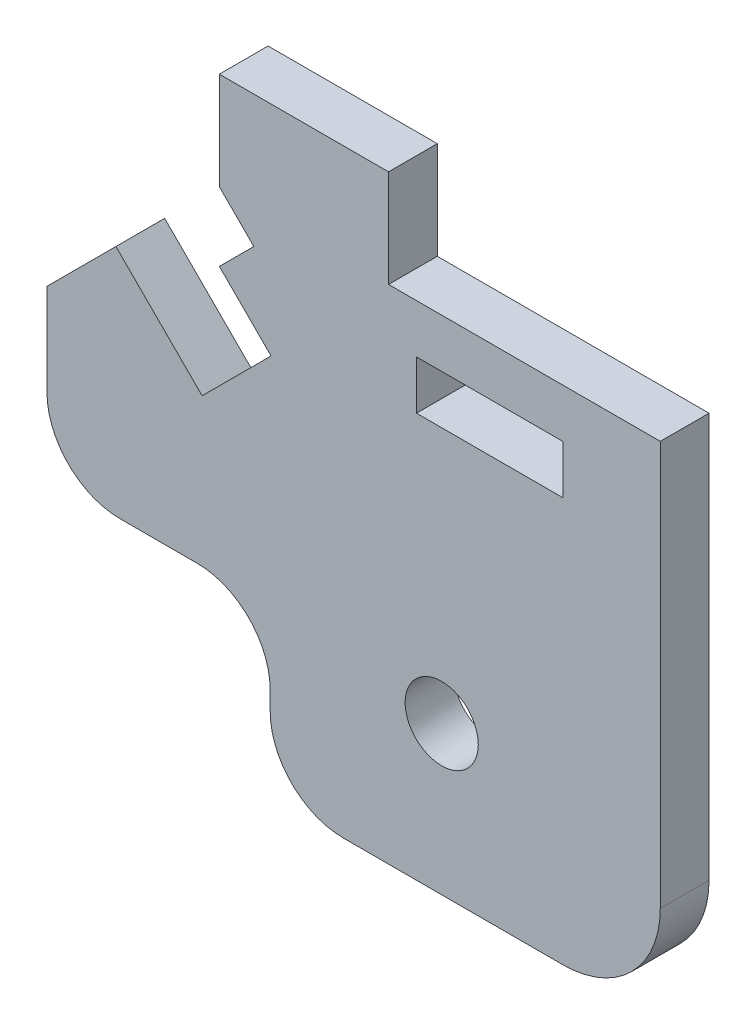
from build123d import *

# Parameters (mm, degrees)
MODEL_R             = 1.5
MODEL_W             = 6
MODEL_H             = 2
BOSS_EXTRUDE1_DEPTH = 2
SKETCH15_W          = 2
SKETCH15_H          = 3
CUT_EXTRUDE1_DEPTH  = 2


with BuildPart() as part:
    # Model → Boss-Extrude1 (new body)
    with BuildSketch(Plane.XY):
        with BuildLine():
            Line((6.363961031, 1.171572875), (2.828427125, 4.707106781))
            Line((2.828427125, 4.707106781), (0, 1.878679656))
            Line((0, 1.878679656), (0, -1.878679656))
            ThreePointArc((0, -1.878679656), (0.878679656, -4), (3, -4.878679656))
            Line((3, -4.878679656), (5.828427125, -4.878679656))
            Line((5.828427125, -4.878679656), (6.156854249, -4.878679656))
            ThreePointArc((6.156854249, -4.878679656), (8.278174593, -5.757359313), (9.156854249, -7.878679656))
            Line((9.156854249, -7.878679656), (9.156854249, -8.641362585))
            ThreePointArc((9.156854249, -8.641362585), (10.035533906, -10.762682929), (12.156854249, -11.641362585))
            Line((12.156854249, -11.641362585), (21.156854249, -11.641362585))
            ThreePointArc((21.156854249, -11.641362585), (23.985281374, -10.46978971), (25.156854249, -7.641362585))
            Line((25.156854249, -7.641362585), (25.156854249, 8.949747468))
            Line((25.156854249, 8.949747468), (14.01040764, 8.949747468))
            Line((14.01040764, 8.949747468), (14.01040764, 12.949747468))
            Line((14.01040764, 12.949747468), (7.071067812, 12.949747468))
            Line((7.071067812, 12.949747468), (7.071067812, 8.949747468))
            Line((7.071067812, 8.949747468), (8.485281374, 7.535533906))
            Line((8.485281374, 7.535533906), (5.656854249, 4.707106781))
            Line((5.656854249, 4.707106781), (7.778174593, 2.585786438))
            Line((7.778174593, 2.585786438), (6.363961031, 1.171572875))
        make_face()
        with Locations((16.191687414, -5.558946351)):
            Circle(MODEL_R, mode=Mode.SUBTRACT)
        with Locations((18.156854249, 5.949747468)):
            Rectangle(MODEL_W, MODEL_H, mode=Mode.SUBTRACT)
    extrude(amount=BOSS_EXTRUDE1_DEPTH)

    # Sketch15 → Cut-Extrude1 (cut)
    with BuildSketch(Plane(origin=(5.181980515, 5.181980515, 0), x_dir=(0, 0, 1), z_dir=(-0.707106781, -0.707106781, 0))):
        with Locations((1, -2.171572875)):
            Rectangle(SKETCH15_W, SKETCH15_H)
    extrude(amount=-CUT_EXTRUDE1_DEPTH, mode=Mode.SUBTRACT)


solid = part.part
